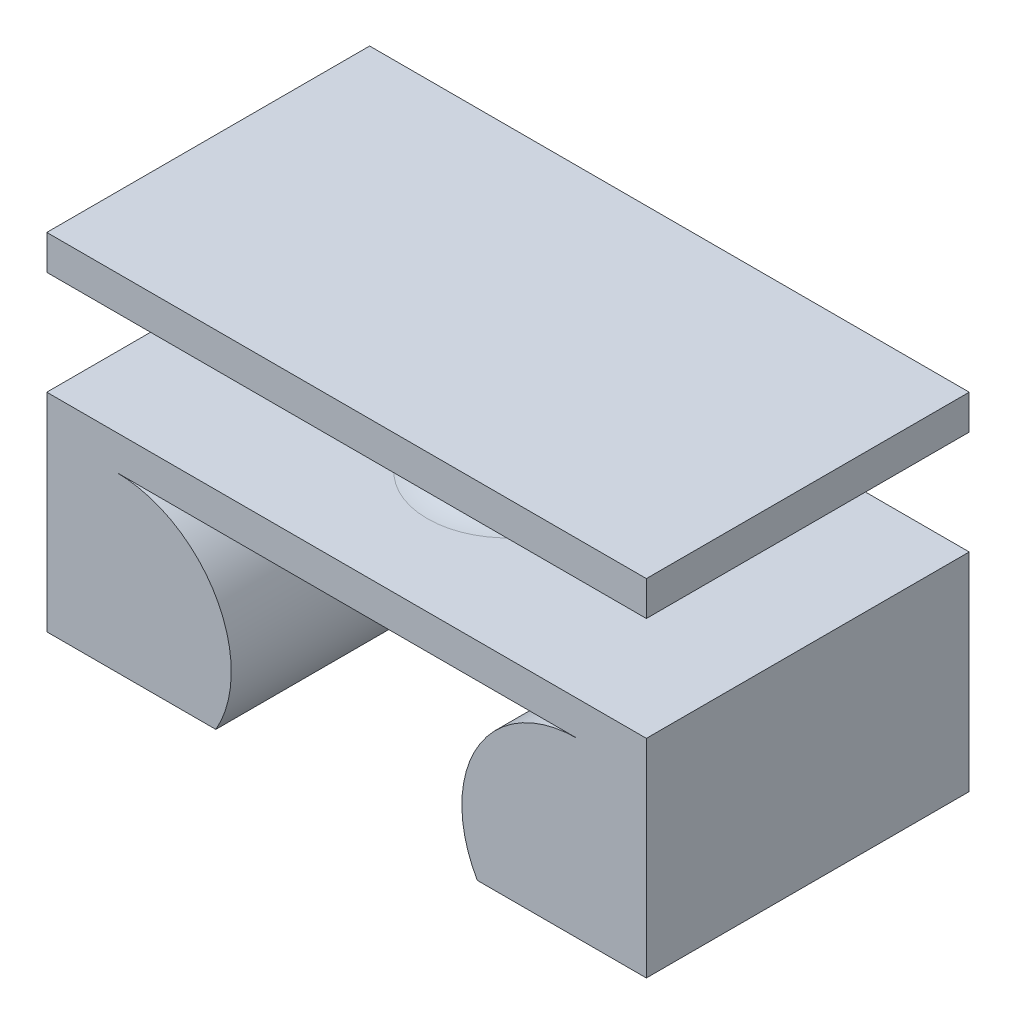
from build123d import *

# Parameters (mm, degrees)
BOSS_EXTRUDE1_DEPTH = 3.5
BOSS_EXTRUDE2_DEPTH = 3.5
SKETCH4_W           = 13
SKETCH4_H           = 7
BOSS_EXTRUDE3_DEPTH = 0.75


with BuildPart() as part:
    # Sketch1 → Boss-Extrude1 (new body, symmetric)
    with BuildSketch(Plane.XY):
        with BuildLine():
            ThreePointArc((-2.834936491, -2.25), (-2.834936491, 0.25), (-5, 1.5))
            Line((-5, 1.5), (5, 1.5))
            ThreePointArc((5, 1.5), (2.834936491, 0.25), (2.834936491, -2.25))
            Line((2.834936491, -2.25), (6.5, -2.25))
            Line((6.5, -2.25), (6.5, 2.25))
            Line((6.5, 2.25), (-6.5, 2.25))
            Line((-6.5, 2.25), (-6.5, -2.25))
            Line((-6.5, -2.25), (-2.834936491, -2.25))
        make_face()
    extrude(amount=BOSS_EXTRUDE1_DEPTH, both=True)

    # Sketch2 → Boss-Extrude2 (add, symmetric)
    with BuildSketch(Plane(origin=(0, 0, 0), x_dir=(0, 0, -1), z_dir=(1, 0, 0))):
        with BuildLine():
            Line((3.5, -2.25), (3.5, 1))
            ThreePointArc((3.5, 1), (2.550755702, -0.498799074), (2.834936491, -2.25))
            Line((2.834936491, -2.25), (3.5, -2.25))
        make_face()
    extrude(amount=BOSS_EXTRUDE2_DEPTH, both=True)

    # Sketch3 → Revolve1 (revolve)
    with BuildSketch(Plane.XY):
        with BuildLine():
            Line((0, 4.5), (-1.75, 4.5))
            ThreePointArc((-1.75, 4.5), (-0.625, 3.375), (-1.75, 2.25))
            Line((-1.75, 2.25), (0, 2.25))
            Line((0, 2.25), (0, 4.5))
        make_face()
    revolve(axis=Axis((0, 5.875, 0), (0, -1, 0)))

    # Sketch4 → Boss-Extrude3 (add)
    with BuildSketch(Plane(origin=(0, 4.5, 0), x_dir=(1, 0, 0), z_dir=(0, 1, 0))):
        Rectangle(SKETCH4_W, SKETCH4_H)
    extrude(amount=BOSS_EXTRUDE3_DEPTH)


solid = part.part
